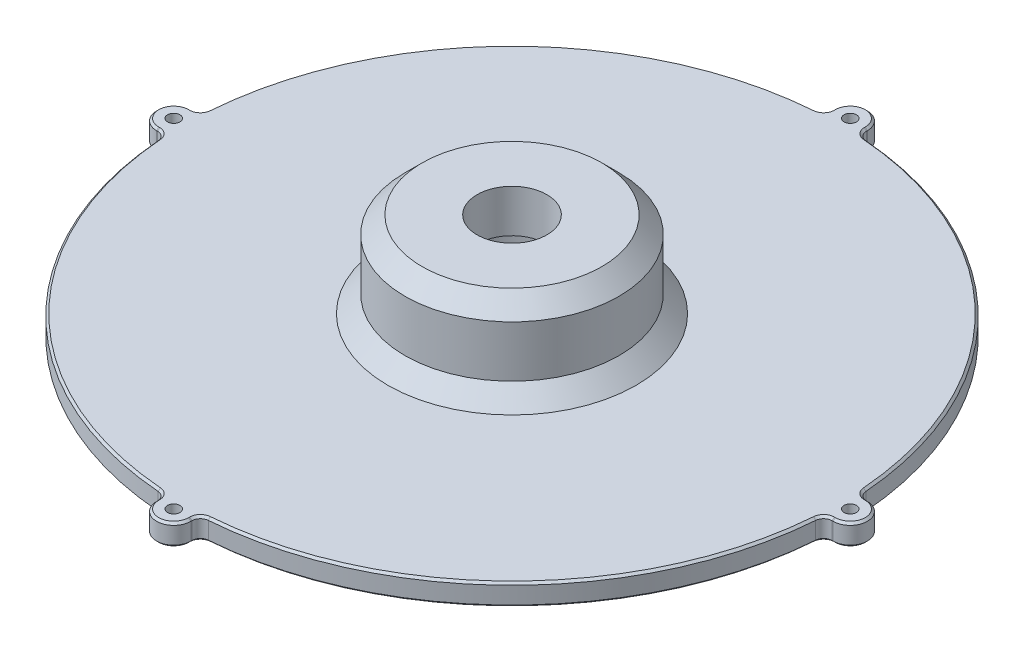
from build123d import *

# Parameters (mm, degrees)
SZKIC2_W                    = 62
SZKIC2_H                    = 5
SZKIC3_R                    = 1.45
DODANIE_WYCI_GNI_CIE1_DEPTH = 5
SFAZOWANIE1_SIZE            = 4
ZAOKR_GLENIE1_R             = 2
SFAZOWANIE2_SIZE            = 0.5


with BuildPart() as part:
    # Szkic2 → Obrót1 (revolve)
    with BuildSketch(Plane.XY):
        Polygon((15, 15), (15, 5), (25, 5), (25, 25), (8.15, 25), (8.15, 15), align=None)
        with Locations((46, 2.5)):
            Rectangle(SZKIC2_W, SZKIC2_H)
    revolve(axis=Axis((0, 0, 0), (0, 1, 0)))

    # Szkic3 → Dodanie-wyciągnięcie1 (add)
    with BuildSketch(Plane(origin=(0, 5, 0), x_dir=(1, 0, 0), z_dir=(0, 1, 0))):
        with BuildLine():
            Line((-4, 76.5), (-4, 79))
            ThreePointArc((-4, 79), (0, 83), (4, 79))
            Line((4, 79), (4, 76.5))
            ThreePointArc((4, 76.5), (0, 72.5), (-4, 76.5))
        make_face()
        with Locations((0, 79)):
            Circle(SZKIC3_R, mode=Mode.SUBTRACT)
        with BuildLine():
            Line((76.5, 4), (79, 4))
            ThreePointArc((79, 4), (83, 0), (79, -4))
            Line((79, -4), (76.5, -4))
            ThreePointArc((76.5, -4), (72.5, 0), (76.5, 4))
        make_face()
        with Locations((79, 0)):
            Circle(SZKIC3_R, mode=Mode.SUBTRACT)
        with BuildLine():
            Line((4, -76.5), (4, -79))
            ThreePointArc((4, -79), (0, -83), (-4, -79))
            Line((-4, -79), (-4, -76.5))
            ThreePointArc((-4, -76.5), (0, -72.5), (4, -76.5))
        make_face()
        with Locations((0, -79)):
            Circle(SZKIC3_R, mode=Mode.SUBTRACT)
        with BuildLine():
            Line((-76.5, -4), (-79, -4))
            ThreePointArc((-79, -4), (-83, 0), (-79, 4))
            Line((-79, 4), (-76.5, 4))
            ThreePointArc((-76.5, 4), (-72.5, 0), (-76.5, -4))
        make_face()
        with Locations((-79, 0)):
            Circle(SZKIC3_R, mode=Mode.SUBTRACT)
    extrude(amount=-DODANIE_WYCI_GNI_CIE1_DEPTH)

    # Sfazowanie1
    sfazowanie1_edges = [part.edges().sort_by_distance(p)[0] for p in [
        (-25, 25, 0),
        (-25, 5, 0),
    ]]
    chamfer(sfazowanie1_edges, length=SFAZOWANIE1_SIZE)

    # Zaokrąglenie1
    zaokr_glenie1_edges = [part.edges().sort_by_distance(p)[0] for p in [
        (-76.896033708, 2.5, -4),
        (-76.896033708, 2.5, 4),
        (-4, 2.5, 76.896033708),
        (4, 2.5, 76.896033708),
        (76.896033708, 2.5, 4),
        (76.896033708, 2.5, -4),
        (4, 2.5, -76.896033708),
        (-4, 2.5, -76.896033708),
    ]]
    fillet(zaokr_glenie1_edges, radius=ZAOKR_GLENIE1_R)

    # Sfazowanie2
    sfazowanie2_edges = [part.edges().sort_by_distance(p)[0] for p in [
        (4, 5, -78.885911187),
        (4, 0, -78.885911187),
        (-4, 5, -78.885911187),
        (-4, 0, -78.885911187),
        (77.41237349, 5, 4.53306485),
        (77.41237349, 0, 4.53306485),
        (77.41237349, 5, -4.53306485),
        (77.41237349, 0, -4.53306485),
        (4.53306485, 5, 77.41237349),
        (4.53306485, 0, 77.41237349),
        (-4.53306485, 5, 77.41237349),
        (-4.53306485, 0, 77.41237349),
        (-77.41237349, 5, 4.53306485),
        (-77.41237349, 0, 4.53306485),
        (-77.41237349, 5, -4.53306485),
        (-77.41237349, 0, -4.53306485),
        (4.53306485, 5, -77.41237349),
        (4.53306485, 0, -77.41237349),
        (-4.53306485, 5, -77.41237349),
        (-4.53306485, 0, -77.41237349),
        (-83, 0, 0),
        (-80.45, 0, 0),
        (-83, 5, 0),
        (0, 0, 83),
        (-1.45, 0, 79),
        (0, 5, 83),
        (83, 0, 0),
        (77.55, 0, 0),
        (83, 5, 0),
        (0, 0, -83),
        (-1.45, 0, -79),
        (0, 5, -83),
        (-15, 0, 0),
        (54.447222151, 5, 54.447222151),
        (54.447222151, 0, 54.447222151),
        (78.885911187, 5, 4),
        (78.885911187, 0, 4),
        (78.885911187, 5, -4),
        (78.885911187, 0, -4),
        (54.447222151, 5, -54.447222151),
        (54.447222151, 0, -54.447222151),
        (4, 5, 78.885911187),
        (4, 0, 78.885911187),
        (-54.447222151, 5, 54.447222151),
        (-54.447222151, 0, 54.447222151),
        (-4, 5, 78.885911187),
        (-4, 0, 78.885911187),
        (-78.885911187, 5, 4),
        (-78.885911187, 0, 4),
        (-54.447222151, 5, -54.447222151),
        (-54.447222151, 0, -54.447222151),
        (-78.885911187, 5, -4),
        (-78.885911187, 0, -4),
    ]]
    chamfer(sfazowanie2_edges, length=SFAZOWANIE2_SIZE)


solid = part.part
